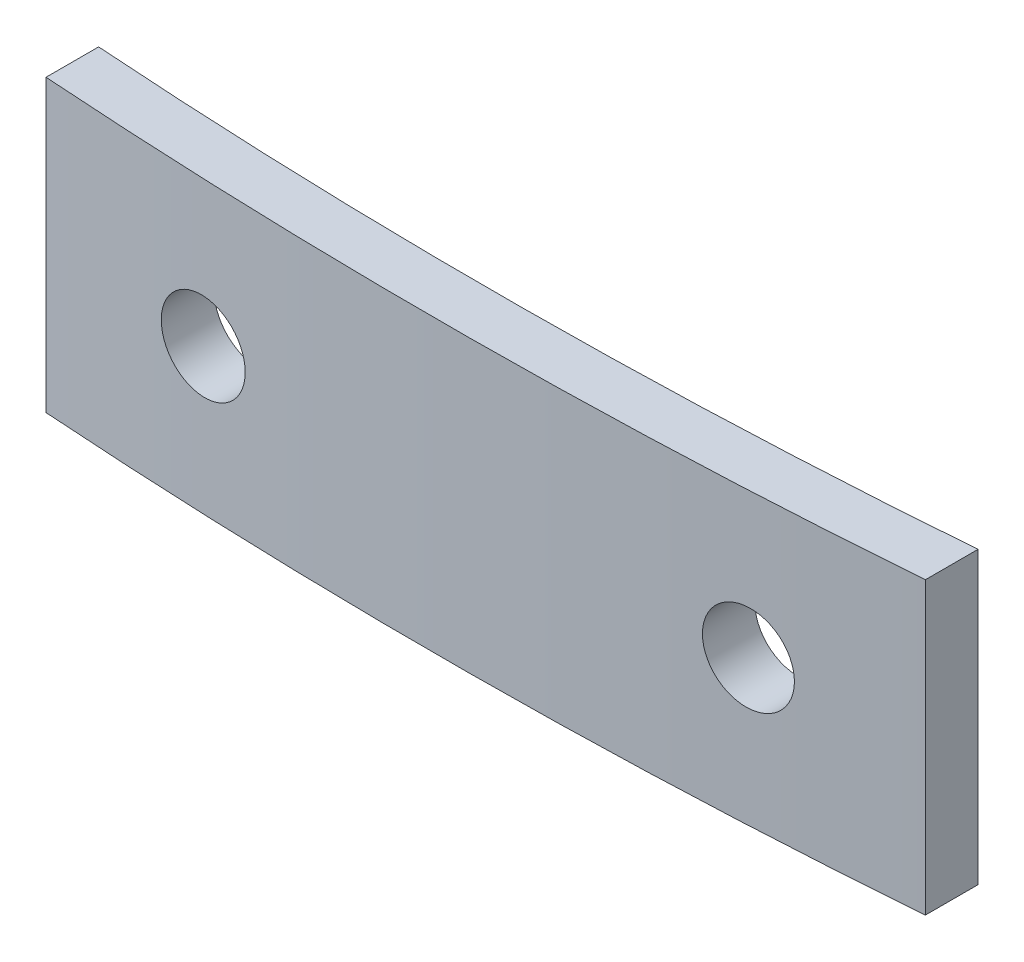
from build123d import *

# Parameters (mm, degrees)
BOSS_EXTRUDE1_DEPTH     = 8.3
SKETCH2_R               = 1.25
CUT_EXTRUDE1_DEPTH      = 5.200074126
CUT_EXTRUDE1_DEPTH_BACK = 1


with BuildPart() as part:
    # Sketch1 → Boss-Extrude1 (new body)
    with BuildSketch(Plane(origin=(0, 0, 0), x_dir=(1, 0, 0), z_dir=(0, 1, 0))):
        with BuildLine():
            Line((-12.5, -2.294781514), (-12.5, -3.798393593))
            ThreePointArc((-12.5, -3.798393593), (0.00238398, -4.197844622), (12.5, -3.669867249))
            Line((12.5, -3.669867249), (12.5, -2.165095715))
            ThreePointArc((12.5, -2.165095715), (0.002427126, -2.697824398), (-12.5, -2.294781514))
        make_face()
    extrude(amount=BOSS_EXTRUDE1_DEPTH)

    # Sketch2 → Cut-Extrude1 (cut, two sides)
    with BuildSketch(Plane.XY) as cut_extrude1_sk:
        with Locations((-7.75, 4.15)):
            Circle(SKETCH2_R)
        with Locations((7.75, 4.15)):
            Circle(SKETCH2_R)
    extrude(amount=CUT_EXTRUDE1_DEPTH, mode=Mode.SUBTRACT)
    extrude(cut_extrude1_sk.sketch, amount=-CUT_EXTRUDE1_DEPTH_BACK, mode=Mode.SUBTRACT)


solid = part.part
